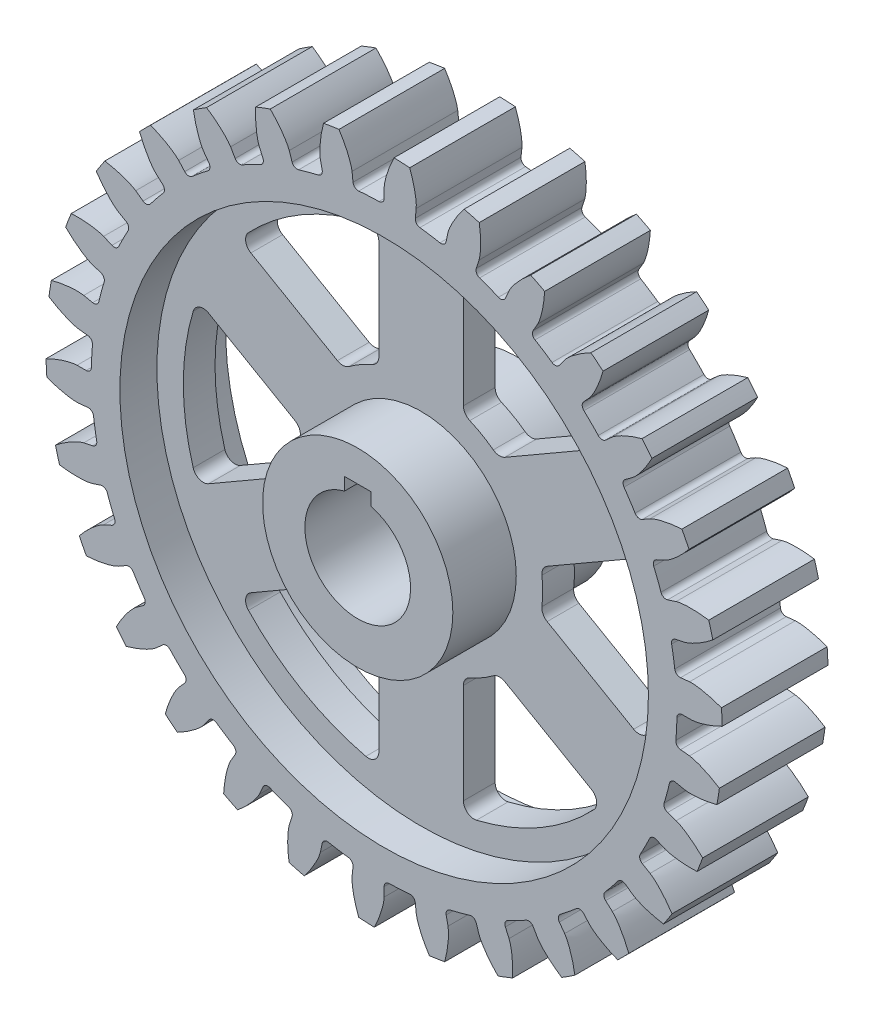
from build123d import *

# Parameters (mm, degrees)
BOSS_EXTRUDE1_START      = -12.7
BOSS_EXTRUDE1_DEPTH      = 25.4
FILLET1_R                = 1.27
CIRPATTERN1_COUNT        = 30
FILLET1_OF_CIRPATTERN1_R = 1.27
CUT_EXTRUDE1_DEPTH       = 20.05
CUT_EXTRUDE1_DEPTH_BACK  = 20.05
CUT_EXTRUDE3_DEPTH       = 20.05
FILLET3_R                = 2.54
CIRPATTERN4_COUNT        = 6
FILLET3_OF_CIRPATTERN4_R = 2.54


with BuildPart() as part:
    # Sketch1 → Revolve1 (revolve)
    with BuildSketch(Plane(origin=(0, 0, 0), x_dir=(0, 0, -1), z_dir=(1, 0, 0))):
        Polygon((0, 0), (19.05, 0), (19.05, 22.86), (3.81, 22.86), (3.81, 63.5), (12.7, 63.5), (12.7, 70.358), (-12.7, 70.358), (-12.7, 63.5), (-3.81, 63.5), (-3.81, 22.86), (-19.05, 22.86), (-19.05, 0), align=None)
    revolve(axis=Axis((0, 0, 19.05), (0, 0, -1)))

    # Sketch2 → Boss-Extrude1 (add)
    with BuildSketch(Plane.XY.offset(BOSS_EXTRUDE1_START)):
        with BuildLine():
            Line((73.787, 0), (70.358, 0))
            ThreePointArc((70.358, 0), (70.261576806, 3.682253209), (69.972571514, 7.354413619))
            Line((69.972571514, 7.354413619), (73.382787145, 7.712841723))
            add(Edge.make_bspline(
                [(73.382787145, 7.712841723), (73.437159922, 7.717395806), (73.589918392, 7.726601961), (73.879547776, 7.729925231), (74.352319742, 7.715277142), (74.954131265, 7.667213704), (75.729922012, 7.571305623), (76.639687369, 7.415196265), (77.633599697, 7.198449314), (78.900762177, 6.863221988), (79.886635477, 6.550497629), (80.600035079, 6.299317676), (81.048363888, 6.131974482)],
                knots=[0, 0, 0, 0, 0, 0.005376748, 0.015083688, 0.02853182, 0.046610139, 0.064854849, 0.092110525, 0.119476175, 0.146842495, 0.194009378, 0.194009378, 0.194009378, 0.194009378, 0.194009378], degree=4))
            ThreePointArc((81.048363888, 6.131974482), (81.168608588, 4.253866467), (81.245338343, 2.373477931))
            add(Edge.make_bspline(
                [(73.787, 0), (73.841550948, 0.001154368), (73.994434897, 0.007966253), (74.282825037, 0.034935703), (74.751475967, 0.098921675), (75.344966706, 0.20962825), (76.106482465, 0.386103151), (76.994946161, 0.6364537), (77.960757507, 0.955905417), (79.185937542, 1.421750879), (80.133721528, 1.835813923), (80.816957598, 2.16018845), (81.245338343, 2.373477931)],
                knots=[0, 0, 0, 0, 0, 0.005376748, 0.015083688, 0.02853182, 0.046610139, 0.064854849, 0.092110525, 0.119476175, 0.146842495, 0.194009378, 0.194009378, 0.194009378, 0.194009378, 0.194009378], degree=4))
        make_face()
    boss_extrude1 = extrude(amount=BOSS_EXTRUDE1_DEPTH)

    # Fillet1
    fillet1_edges = [part.edges().sort_by_distance(p)[0] for p in [
        (70.358, 0, 0),
        (69.972571514, 7.354413619, 0),
    ]]
    fillet(fillet1_edges, radius=FILLET1_R)

    # CirPattern1: Boss-Extrude1 ×30 about axis
    cirpattern1_axis = Axis((0, 0, 20.955), (0, 0, -1))
    for i in range(1, CIRPATTERN1_COUNT):
        add(boss_extrude1.rotate(cirpattern1_axis, i * 360 / CIRPATTERN1_COUNT))

    # Fillet1 of CirPattern1
    fillet1_of_cirpattern1_edges = [part.edges().sort_by_distance(p)[0] for p in [
        (68.820508892, -14.628250743, 0),
        (69.972571514, -7.354413619, 0),
        (64.275231309, -28.617176734, 0),
        (66.914434373, -21.74181769, 0),
        (56.92081769, -41.355394781, 0),
        (60.931815359, -35.179, 0),
        (47.078691202, -52.286183631, 0),
        (52.286183631, -47.078691202, 0),
        (35.179, -60.931815359, 0),
        (41.355394781, -56.92081769, 0),
        (21.74181769, -66.914434373, 0),
        (28.617176734, -64.275231309, 0),
        (7.354413619, -69.972571514, 0),
        (14.628250743, -68.820508892, 0),
        (-7.354413619, -69.972571514, 0),
        (0, -70.358, 0),
        (-21.74181769, -66.914434373, 0),
        (-14.628250743, -68.820508892, 0),
        (-35.179, -60.931815359, 0),
        (-28.617176734, -64.275231309, 0),
        (-47.078691202, -52.286183631, 0),
        (-41.355394781, -56.92081769, 0),
        (-56.92081769, -41.355394781, 0),
        (-52.286183631, -47.078691202, 0),
        (-64.275231309, -28.617176734, 0),
        (-60.931815359, -35.179, 0),
        (-68.820508892, -14.628250743, 0),
        (-66.914434373, -21.74181769, 0),
        (-70.358, 0, 0),
        (-69.972571514, -7.354413619, 0),
        (-68.820508892, 14.628250743, 0),
        (-69.972571514, 7.354413619, 0),
        (-64.275231309, 28.617176734, 0),
        (-66.914434373, 21.74181769, 0),
        (-56.92081769, 41.355394781, 0),
        (-60.931815359, 35.179, 0),
        (-47.078691202, 52.286183631, 0),
        (-52.286183631, 47.078691202, 0),
        (-35.179, 60.931815359, 0),
        (-41.355394781, 56.92081769, 0),
        (-21.74181769, 66.914434373, 0),
        (-28.617176734, 64.275231309, 0),
        (-7.354413619, 69.972571514, 0),
        (-14.628250743, 68.820508892, 0),
        (7.354413619, 69.972571514, 0),
        (0, 70.358, 0),
        (21.74181769, 66.914434373, 0),
        (14.628250743, 68.820508892, 0),
        (35.179, 60.931815359, 0),
        (28.617176734, 64.275231309, 0),
        (47.078691202, 52.286183631, 0),
        (41.355394781, 56.92081769, 0),
        (56.92081769, 41.355394781, 0),
        (52.286183631, 47.078691202, 0),
        (64.275231309, 28.617176734, 0),
        (60.931815359, 35.179, 0),
        (68.820508892, 14.628250743, 0),
        (66.914434373, 21.74181769, 0),
    ]]
    fillet(fillet1_of_cirpattern1_edges, radius=FILLET1_OF_CIRPATTERN1_R)

    # Sketch3 → Cut-Extrude1 (cut, two sides)
    with BuildSketch(Plane.XY) as cut_extrude1_sk:
        with BuildLine():
            Line((-3.175, 12.296722124), (-3.175, 15.344722124))
            Line((-3.175, 15.344722124), (3.175, 15.344722124))
            Line((3.175, 15.344722124), (3.175, 12.296722124))
            ThreePointArc((3.175, 12.296722124), (0, -12.7), (-3.175, 12.296722124))
        make_face()
    extrude(amount=CUT_EXTRUDE1_DEPTH, mode=Mode.SUBTRACT)
    extrude(cut_extrude1_sk.sketch, amount=-CUT_EXTRUDE1_DEPTH_BACK, mode=Mode.SUBTRACT)

    # Sketch4 → Cut-Extrude3 (cut, symmetric)
    with BuildSketch(Plane.XY):
        with BuildLine():
            Line((18.637058734, 22.491868347), (43.624955343, 36.918637181))
            ThreePointArc((43.624955343, 36.918637181), (28.575, 49.493351826), (10.16, 56.239638157))
            Line((10.16, 56.239638157), (10.16, 27.386100489))
            ThreePointArc((10.16, 27.386100489), (14.605, 25.296602045), (18.637058734, 22.491868347))
        make_face()
    cut_extrude3 = extrude(amount=CUT_EXTRUDE3_DEPTH, both=True, mode=Mode.SUBTRACT)

    # Fillet3
    fillet3_edges = [part.edges().sort_by_distance(p)[0] for p in [
        (43.624955343, 36.918637181, 0),
        (18.637058734, 22.491868347, 0),
        (10.16, 27.386100489, 0),
        (10.16, 56.239638157, 0),
    ]]
    fillet(fillet3_edges, radius=FILLET3_R)

    # CirPattern4: Cut-Extrude3 ×6 about axis
    cirpattern4_axis = Axis((0, 0, 0), (0, 0, 1))
    for i in range(1, CIRPATTERN4_COUNT):
        add(cut_extrude3.rotate(cirpattern4_axis, i * 360 / CIRPATTERN4_COUNT), mode=Mode.SUBTRACT)

    # Fillet3 of CirPattern4
    fillet3_of_cirpattern4_edges = [part.edges().sort_by_distance(p)[0] for p in [
        (-10.16, 56.239638157, 0),
        (-10.16, 27.386100489, 0),
        (-18.637058734, 22.491868347, 0),
        (-43.624955343, 36.918637181, 0),
        (-53.784955343, 19.321000976, 0),
        (-28.797058734, 4.894232142, 0),
        (-28.797058734, -4.894232142, 0),
        (-53.784955343, -19.321000976, 0),
        (-43.624955343, -36.918637181, 0),
        (-18.637058734, -22.491868347, 0),
        (-10.16, -27.386100489, 0),
        (-10.16, -56.239638157, 0),
        (10.16, -56.239638157, 0),
        (10.16, -27.386100489, 0),
        (18.637058734, -22.491868347, 0),
        (43.624955343, -36.918637181, 0),
        (53.784955343, -19.321000976, 0),
        (28.797058734, -4.894232142, 0),
        (28.797058734, 4.894232142, 0),
        (53.784955343, 19.321000976, 0),
    ]]
    fillet(fillet3_of_cirpattern4_edges, radius=FILLET3_OF_CIRPATTERN4_R)


solid = part.part
